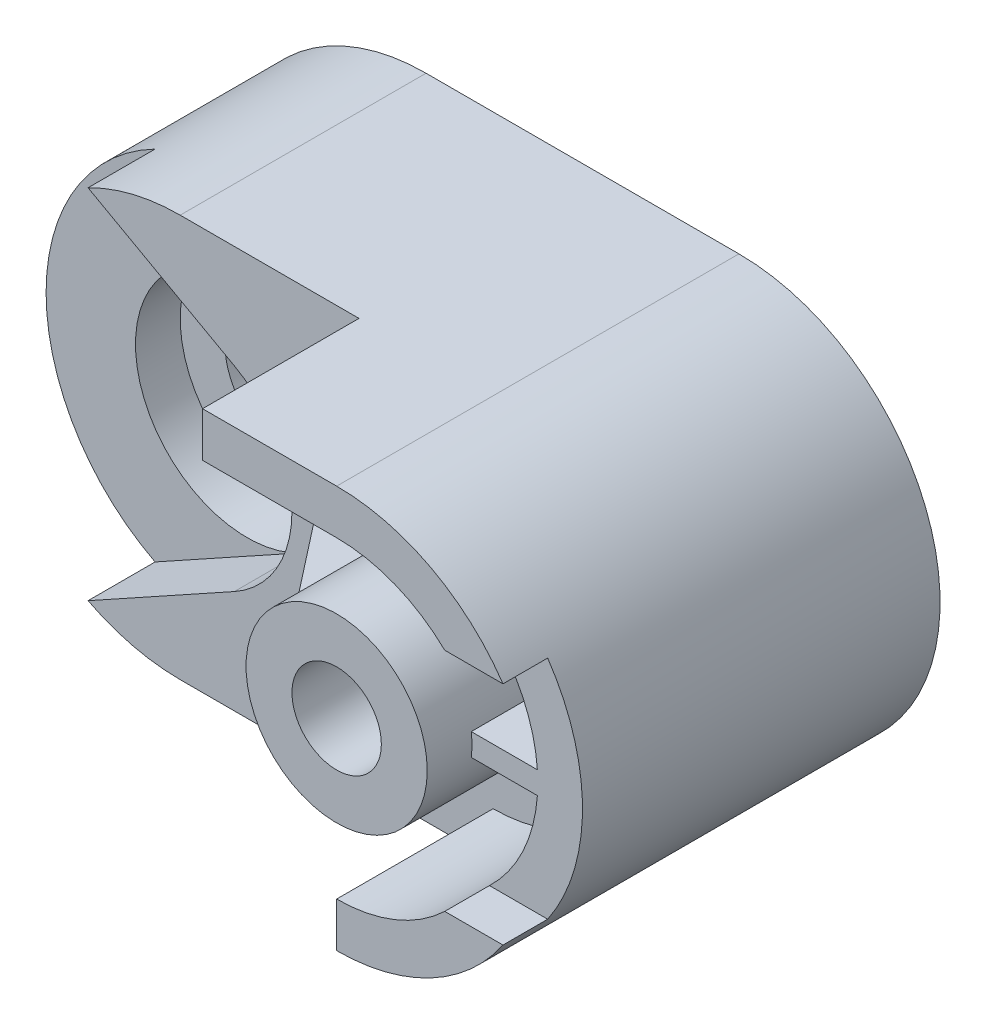
from build123d import *

# Parameters (mm, degrees)
BOSS_EXTRUDE1_DEPTH = 90
CUT_EXTRUDE1_DEPTH  = 10
SKETCH3_R           = 10
CUT_EXTRUDE2_DEPTH  = 166
SKETCH4_R           = 25
CUT_EXTRUDE3_DEPTH  = 50
SKETCH5_R           = 25
CUT_EXTRUDE4_DEPTH  = 10
SKETCH6_R           = 15
CUT_EXTRUDE5_DEPTH  = 148
CUT_EXTRUDE6_DEPTH  = 35
SKETCH8_W           = 10
SKETCH8_H           = 5
CUT_EXTRUDE7_DEPTH  = 145
SKETCH9_W           = 20
SKETCH9_H           = 10
BOSS_EXTRUDE2_DEPTH = 25
CUT_EXTRUDE8_DEPTH  = 10
CUT_EXTRUDE9_DEPTH  = 25
CUT_EXTRUDE10_DEPTH = 25
CUT_EXTRUDE11_DEPTH = 10


with BuildPart() as part:
    # Sketch1 → Boss-Extrude1 (new body)
    with BuildSketch(Plane.XY):
        with BuildLine():
            Line((0, 45), (70, 45))
            ThreePointArc((70, 45), (115, 0), (70, -45))
            Line((70, -45), (0, -45))
            ThreePointArc((0, -45), (-45, 0), (0, 45))
        make_face()
    extrude(amount=BOSS_EXTRUDE1_DEPTH)

    # Sketch2 → Cut-Extrude1 (cut)
    with BuildSketch(Plane(origin=(0, 0, 0), x_dir=(-1, 0, 0), z_dir=(0, 0, -1))):
        with BuildLine():
            Line((0, -25), (-70, -25))
            ThreePointArc((-70, -25), (-95, 0), (-70, 25))
            Line((-70, 25), (0, 25))
            ThreePointArc((0, 25), (25, 0), (0, -25))
        make_face()
    extrude(amount=-CUT_EXTRUDE1_DEPTH, mode=Mode.SUBTRACT)

    # Sketch3 → Cut-Extrude2 (cut)
    with BuildSketch(Plane.XY.offset(90)):
        with Locations((70, 0)):
            Circle(SKETCH3_R)
    extrude(amount=-CUT_EXTRUDE2_DEPTH, mode=Mode.SUBTRACT)

    # Sketch4 → Cut-Extrude3 (cut)
    with BuildSketch(Plane.XY.offset(90)):
        with BuildLine():
            ThreePointArc((12.114503105, -21.868671988), (-25, 0), (12.114503105, 21.868671988))
            Line((12.114503105, 21.868671988), (-20.615528128, 40))
            ThreePointArc((-20.615528128, 40), (-45, 0), (-20.615528128, -40))
            Line((-20.615528128, -40), (12.114503105, -21.868671988))
        make_face()
        Circle(SKETCH4_R)
    extrude(amount=-CUT_EXTRUDE3_DEPTH, mode=Mode.SUBTRACT)

    # Sketch5 → Cut-Extrude4 (cut)
    with BuildSketch(Plane.XY.offset(40)):
        Circle(SKETCH5_R)
    extrude(amount=-CUT_EXTRUDE4_DEPTH, mode=Mode.SUBTRACT)

    # Sketch6 → Cut-Extrude5 (cut)
    with BuildSketch(Plane.XY.offset(30)):
        Circle(SKETCH6_R)
    extrude(amount=-CUT_EXTRUDE5_DEPTH, mode=Mode.SUBTRACT)

    # Sketch7 → Cut-Extrude6 (cut)
    with BuildSketch(Plane.XY.offset(90)):
        with BuildLine():
            Line((40, 45), (0, 45))
            ThreePointArc((0, 45), (-10.606601718, 43.732139211), (-20.615528128, 40))
            Line((-20.615528128, 40), (12.114503105, 21.868671988))
            ThreePointArc((12.114503105, 21.868671988), (25, 0), (12.114503105, -21.868671988))
            Line((12.114503105, -21.868671988), (-20.615528128, -40))
            ThreePointArc((-20.615528128, -40), (-10.606601718, -43.732139211), (0, -45))
            Line((0, -45), (70, -45))
            Line((70, -45), (70, -35))
            ThreePointArc((70, -35), (92.912878475, -26.457513111), (104.641016151, -5))
            Line((104.641016151, -5), (89.641016151, -5))
            ThreePointArc((89.641016151, -5), (49.732550346, 0), (89.641016151, 5))
            Line((89.641016151, 5), (104.641016151, 5))
            ThreePointArc((104.641016151, 5), (92.912878475, 26.457513111), (70, 35))
            Line((70, 35), (40, 35))
            Line((40, 35), (40, 45))
        make_face()
    extrude(amount=-CUT_EXTRUDE6_DEPTH, mode=Mode.SUBTRACT)

    # Sketch8 → Cut-Extrude7 (cut)
    with BuildSketch(Plane(origin=(0, 0, 0), x_dir=(0, 0, -1), z_dir=(1, 0, 0))):
        with Locations((-85, 22.8)):
            Rectangle(SKETCH8_W, SKETCH8_H)
        with Locations((-85, -22.8)):
            Rectangle(SKETCH8_W, SKETCH8_H)
    extrude(amount=CUT_EXTRUDE7_DEPTH, mode=Mode.SUBTRACT)

    # Sketch9 → Boss-Extrude2 (add)
    with BuildSketch(Plane.XY.offset(55)):
        with Locations((40.358983849, 0)):
            Rectangle(SKETCH9_W, SKETCH9_H)
    extrude(amount=BOSS_EXTRUDE2_DEPTH)

    # Sketch10 → Cut-Extrude8 (cut)
    with BuildSketch(Plane.XY.offset(90)):
        with BuildLine():
            Line((89.641016151, 5), (104.641016151, 5))
            ThreePointArc((104.641016151, 5), (102.489767507, 13.015952033), (98.511576596, 20.3))
            Line((98.511576596, 20.3), (110.161050783, 20.3))
            ThreePointArc((110.161050783, 20.3), (115, 0), (110.161050783, -20.3))
            Line((110.161050783, -20.3), (98.511576596, -20.3))
            ThreePointArc((98.511576596, -20.3), (102.489767507, -13.015952033), (104.641016151, -5))
            Line((104.641016151, -5), (89.641016151, -5))
            ThreePointArc((89.641016151, -5), (90.267449654, 0), (89.641016151, 5))
        make_face()
    extrude(amount=-CUT_EXTRUDE8_DEPTH, mode=Mode.SUBTRACT)

    # Sketch11 → Cut-Extrude9 (cut)
    with BuildSketch(Plane.XY.offset(80)):
        with BuildLine():
            Line((49.88732948, -2.5), (30.358983849, -2.5))
            Line((30.358983849, -2.5), (30.358983849, -5))
            Line((30.358983849, -5), (50.358983849, -5))
            ThreePointArc((50.358983849, -5), (50.083890917, -3.757407944), (49.88732948, -2.5))
        make_face()
        with BuildLine():
            Line((50.358983849, 5), (30.358983849, 5))
            Line((30.358983849, 5), (30.358983849, 2.5))
            Line((30.358983849, 2.5), (49.88732948, 2.5))
            ThreePointArc((49.88732948, 2.5), (50.083890917, 3.757407944), (50.358983849, 5))
        make_face()
    extrude(amount=-CUT_EXTRUDE9_DEPTH, mode=Mode.SUBTRACT)

    # Sketch12 → Cut-Extrude10 (cut)
    with BuildSketch(Plane.XY.offset(80)):
        with BuildLine():
            Line((104.910600109, -2.5), (90.11267052, -2.5))
            ThreePointArc((90.11267052, -2.5), (89.916109083, -3.757407944), (89.641016151, -5))
            Line((89.641016151, -5), (104.641016151, -5))
            ThreePointArc((104.641016151, -5), (104.798266209, -3.752421735), (104.910600109, -2.5))
        make_face()
        with BuildLine():
            Line((104.641016151, 5), (89.641016151, 5))
            ThreePointArc((89.641016151, 5), (89.916109083, 3.757407944), (90.11267052, 2.5))
            Line((90.11267052, 2.5), (104.910600109, 2.5))
            ThreePointArc((104.910600109, 2.5), (104.798266209, 3.752421735), (104.641016151, 5))
        make_face()
    extrude(amount=-CUT_EXTRUDE10_DEPTH, mode=Mode.SUBTRACT)

    # Sketch13 → Cut-Extrude11 (cut)
    with BuildSketch(Plane.XZ.offset(2.5)):
        Polygon((49.88732948, 80), (30.358983849, 55), (30.358983849, 80), align=None)
    extrude(amount=-CUT_EXTRUDE11_DEPTH, mode=Mode.SUBTRACT)


solid = part.part
